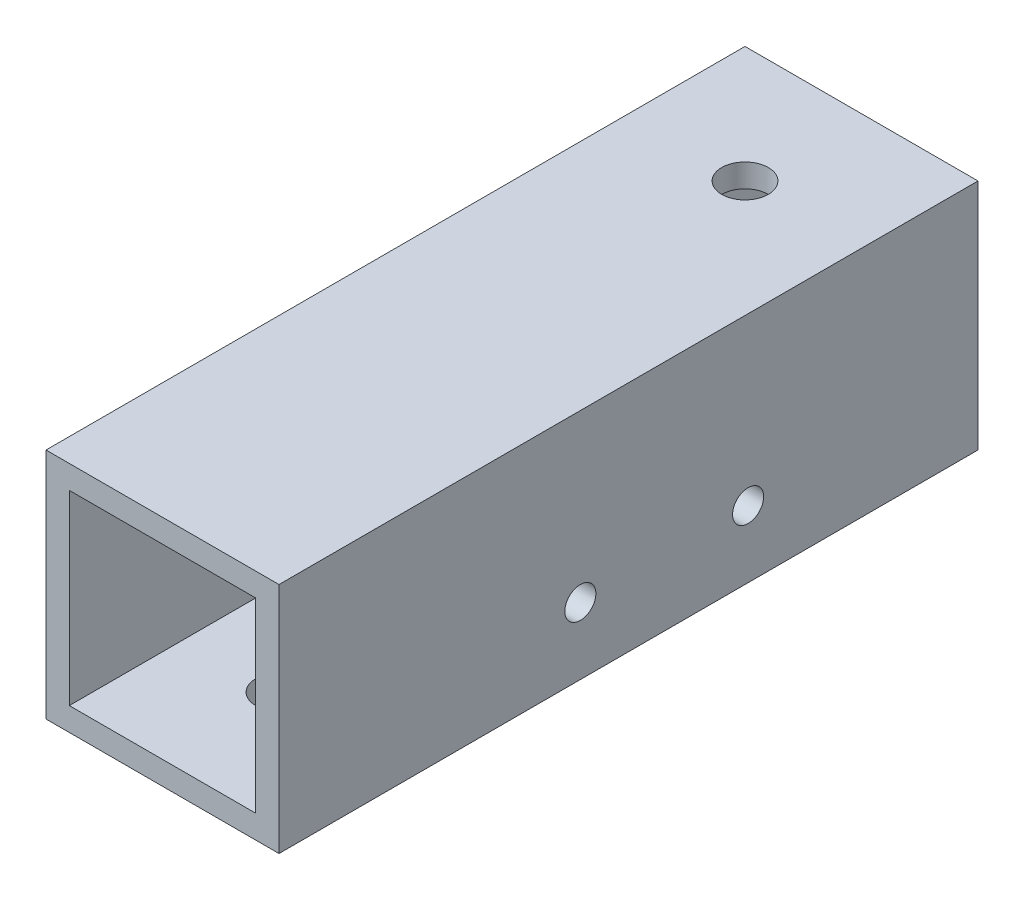
from build123d import *

# Parameters (mm, degrees)
SKETCH_1_W          = 15
SKETCH_1_H          = 15
SKETCH_1_W_2        = 12
SKETCH_1_H_2        = 12
EXTRUDE_2_DEPTH     = 45
SKETCH_2_R          = 1.5
CUT_EXTRUDE_1_DEPTH = 10
SKETCH_3_R          = 1.5
CUT_EXTRUDE_2_DEPTH = 10
SKETCH_4_R          = 1
CUT_EXTRUDE_3_DEPTH = 10
SKETCH_5_R          = 1
CUT_EXTRUDE_4_DEPTH = 10


with BuildPart() as part:
    # ｽｹｯﾁ1 → ﾎﾞｽ - 押し出し2 (new body)
    with BuildSketch(Plane.XY):
        with Locations((0.489915859, 0.232626086)):
            Rectangle(SKETCH_1_W, SKETCH_1_H)
        with Locations((0.489915859, 0.232626086)):
            Rectangle(SKETCH_1_W_2, SKETCH_1_H_2, mode=Mode.SUBTRACT)
    extrude(amount=EXTRUDE_2_DEPTH)

    # ｽｹｯﾁ2 → ｶｯﾄ - 押し出し1 (cut)
    with BuildSketch(Plane(origin=(0, 7.732626086, 0), x_dir=(1, 0, 0), z_dir=(0, 1, 0))):
        with Locations((0.489915859, -7.5)):
            Circle(SKETCH_2_R)
    extrude(amount=-CUT_EXTRUDE_1_DEPTH, mode=Mode.SUBTRACT)

    # ｽｹｯﾁ3 → ｶｯﾄ - 押し出し2 (cut)
    with BuildSketch(Plane.XZ.offset(7.267373914)):
        with Locations((0.489915859, 37.5)):
            Circle(SKETCH_3_R)
    extrude(amount=-CUT_EXTRUDE_2_DEPTH, mode=Mode.SUBTRACT)

    # ｽｹｯﾁ4 → ｶｯﾄ - 押し出し3 (cut)
    with BuildSketch(Plane(origin=(7.989915859, 0, 0), x_dir=(0, 0, -1), z_dir=(1, 0, 0))):
        with Locations((-25.6, -2.967373914)):
            Circle(SKETCH_4_R)
    extrude(amount=-CUT_EXTRUDE_3_DEPTH, mode=Mode.SUBTRACT)

    # ｽｹｯﾁ5 → ｶｯﾄ - 押し出し4 (cut)
    with BuildSketch(Plane(origin=(7.989915859, 0, 0), x_dir=(0, 0, -1), z_dir=(1, 0, 0))):
        with Locations((-14.8, -2.967373914)):
            Circle(SKETCH_5_R)
    extrude(amount=-CUT_EXTRUDE_4_DEPTH, mode=Mode.SUBTRACT)


solid = part.part
